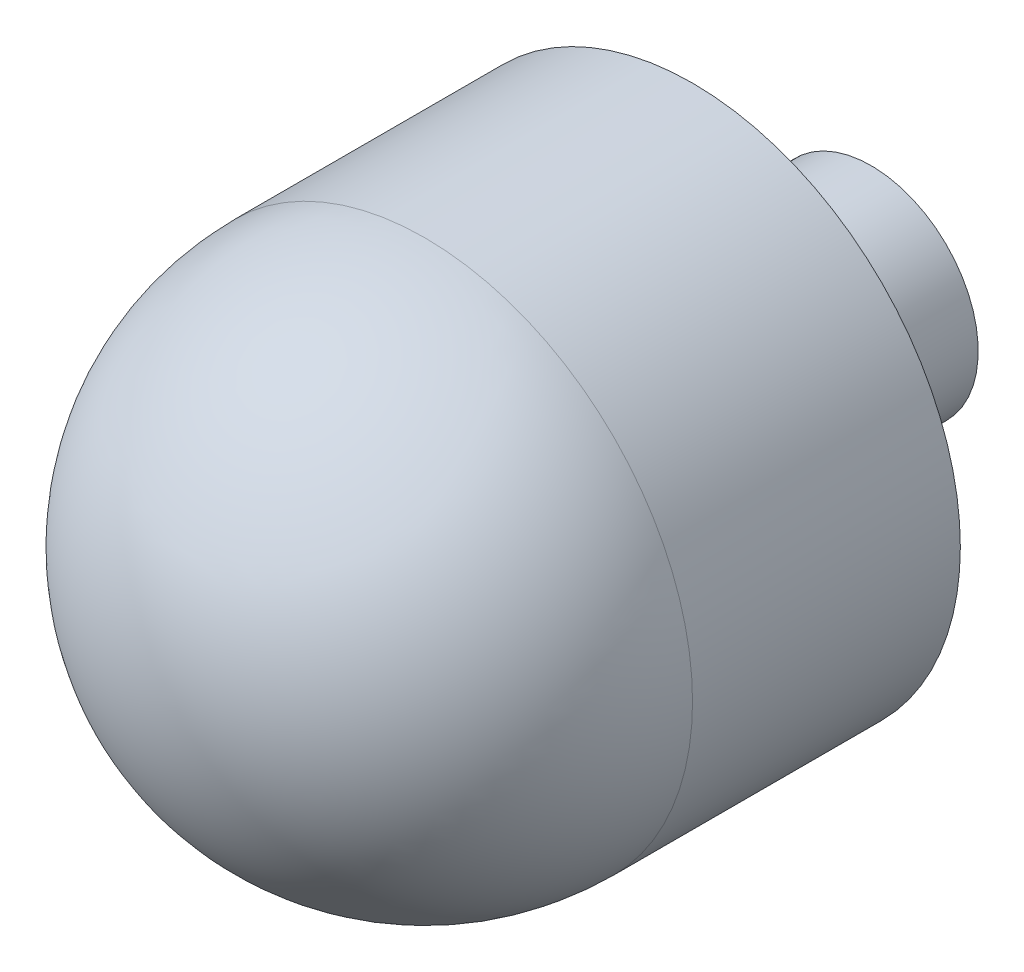
from build123d import *


with BuildPart() as part:
    # Sketch1 → Revolve1 (revolve)
    with BuildSketch(Plane(origin=(0, 0, 0), x_dir=(1, 0, 0), z_dir=(0, 1, 0)), mode=Mode.PRIVATE) as revolve1_sk:
        with BuildLine():
            Line((15, 15), (15, 30))
            Line((15, 30), (6, 30))
            Line((6, 30), (6, 40))
            Line((6, 40), (0, 40))
            Line((0, 40), (0, 0))
            ThreePointArc((0, 0), (10.606601718, 4.393398282), (15, 15))
        make_face()
    revolve(revolve1_sk.sketch.rotate(Axis((0, 0, -105.136363636), (0, 0, 1)), 180), axis=Axis((0, 0, -105.136363636), (0, 0, 1)))  # turned: the seam where the file's is


solid = part.part
